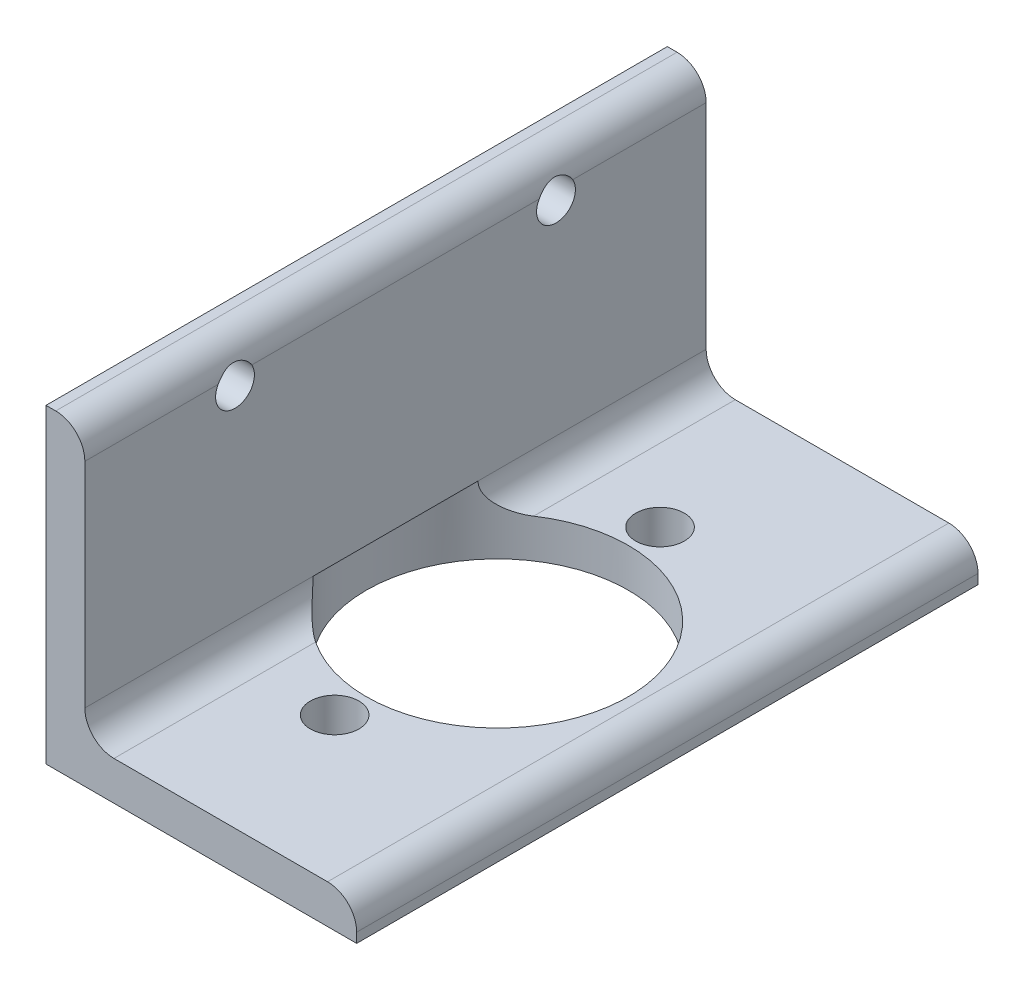
from build123d import *

# Parameters (mm, degrees)
BOSS_EXTRUDE1_DEPTH     = 101.6
SKETCH2_R               = 7.9375
SKETCH2_R_2             = 42.8625
CUT_EXTRUDE1_DEPTH      = 9.525
CUT_EXTRUDE1_DEPTH_BACK = 12.7
CUT_EXTRUDE2_REACH      = 14.7
SKETCH3_R               = 6.35


with BuildPart() as part:
    # Sketch1 → Boss-Extrude1 (new body, symmetric)
    with BuildSketch(Plane.XY):
        with BuildLine():
            Line((0, 0), (0, 101.6))
            Line((0, 101.6), (3.18008, 101.6))
            ThreePointArc((3.18008, 101.6), (9.911679988, 98.811679988), (12.7, 92.08008))
            Line((12.7, 92.08008), (12.7, 22.225))
            ThreePointArc((12.7, 22.225), (15.489807909, 15.489807909), (22.225, 12.7))
            Line((22.225, 12.7), (92.08008, 12.7))
            ThreePointArc((92.08008, 12.7), (98.811679988, 9.911679988), (101.6, 3.18008))
            Line((101.6, 3.18008), (101.6, 0))
            Line((101.6, 0), (0, 0))
        make_face()
    extrude(amount=BOSS_EXTRUDE1_DEPTH, both=True)

    # Sketch2 → Cut-Extrude1 (cut, two sides)
    with BuildSketch(Plane(origin=(0, 12.7, 0), x_dir=(1, 0, 0), z_dir=(0, 1, 0))) as cut_extrude1_sk:
        with Locations((45.9994, 53.213)):
            Circle(SKETCH2_R)
        with Locations((45.9994, -53.213)):
            Circle(SKETCH2_R)
        with Locations((45.9994, 0)):
            Circle(SKETCH2_R_2)
    extrude(amount=CUT_EXTRUDE1_DEPTH, mode=Mode.SUBTRACT)
    extrude(cut_extrude1_sk.sketch, amount=-CUT_EXTRUDE1_DEPTH_BACK, mode=Mode.SUBTRACT)

    # Sketch3 → Cut-Extrude2 (cut, up to next)
    with BuildSketch(Plane(origin=(12.7, 0, 0), x_dir=(0, 0, -1), z_dir=(1, 0, 0)), mode=Mode.PRIVATE) as cut_extrude2_sk1:
        with Locations((52.4891, 88.9)):
            Circle(SKETCH3_R)
    cut_extrude2_tool1 = extrude(cut_extrude2_sk1.sketch, amount=-CUT_EXTRUDE2_REACH, mode=Mode.PRIVATE) & part.part
    add(cut_extrude2_tool1.solids().sort_by_distance((12.7, 88.9, -52.4891))[0], mode=Mode.SUBTRACT)
    # Sketch3 → Cut-Extrude2 (cut, up to next)
    with BuildSketch(Plane(origin=(12.7, 0, 0), x_dir=(0, 0, -1), z_dir=(1, 0, 0)), mode=Mode.PRIVATE) as cut_extrude2_sk2:
        with Locations((-52.4891, 88.9)):
            Circle(SKETCH3_R)
    cut_extrude2_tool2 = extrude(cut_extrude2_sk2.sketch, amount=-CUT_EXTRUDE2_REACH, mode=Mode.PRIVATE) & part.part
    add(cut_extrude2_tool2.solids().sort_by_distance((12.7, 88.9, 52.4891))[0], mode=Mode.SUBTRACT)


solid = part.part
